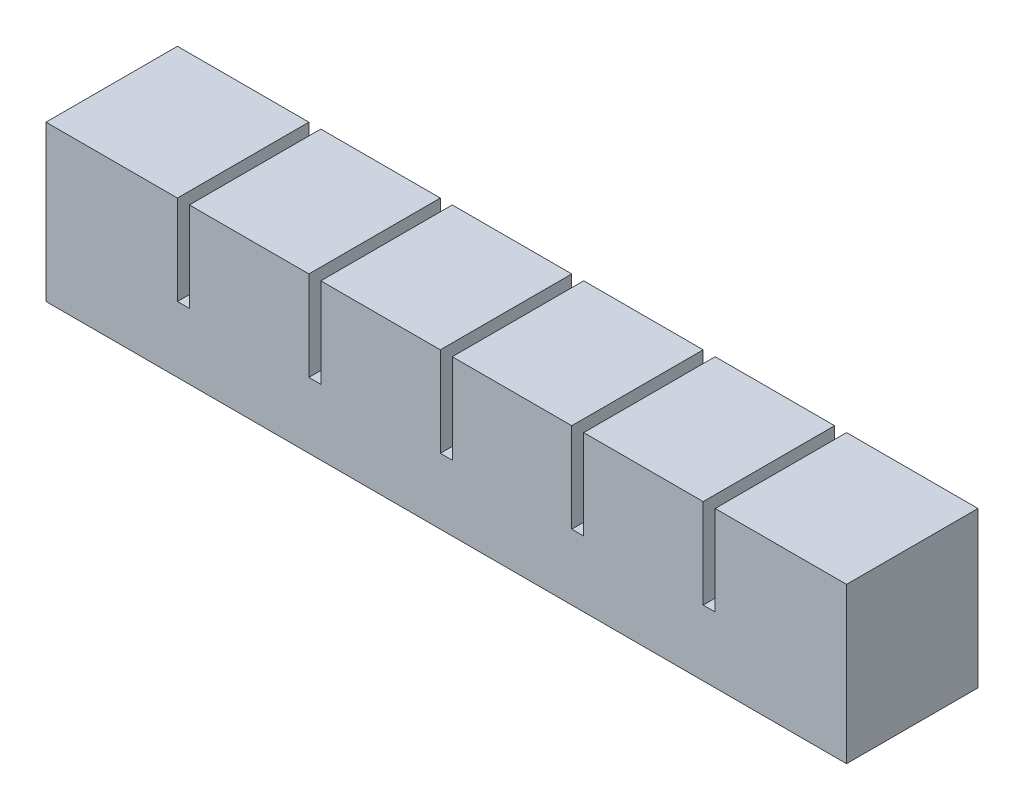
from build123d import *

# Parameters (mm, degrees)
SKETCH1_W           = 20
SKETCH1_H           = 20
BOSS_EXTRUDE1_DEPTH = 22
SKETCH2_W           = 8
SKETCH2_H           = 10
CUT_EXTRUDE1_DEPTH  = 14
SKETCH3_W           = 22
SKETCH3_H           = 5
BOSS_EXTRUDE2_DEPTH = 2
LPATTERN1_COUNT     = 6
LPATTERN1_PITCH     = 22
SKETCH4_W           = 22
SKETCH4_H           = 15
BOSS_EXTRUDE3_DEPTH = 2
SKETCH5_W           = 22
SKETCH5_H           = 20
BOSS_EXTRUDE4_DEPTH = 2
SKETCH6_W           = 118
SKETCH6_H           = 2
CUT_EXTRUDE2_DEPTH  = 2
SKETCH7_W           = 134
SKETCH7_H           = 22
BOSS_EXTRUDE5_DEPTH = 6


with BuildPart() as part:
    # Sketch1 → Boss-Extrude1 (new body)
    with BuildSketch(Plane.XY):
        with Locations((10, 10)):
            Rectangle(SKETCH1_W, SKETCH1_H)
    extrude(amount=BOSS_EXTRUDE1_DEPTH)

    # Sketch2 → Cut-Extrude1 (cut)
    with BuildSketch(Plane.XZ):
        with Locations((10, 11)):
            Rectangle(SKETCH2_W, SKETCH2_H)
    extrude(amount=-CUT_EXTRUDE1_DEPTH, mode=Mode.SUBTRACT)

    # Sketch3 → Boss-Extrude2 (add)
    with BuildSketch(Plane(origin=(20, 0, 0), x_dir=(0, 0, -1), z_dir=(1, 0, 0))):
        with Locations((-11, 2.5)):
            Rectangle(SKETCH3_W, SKETCH3_H)
    extrude(amount=BOSS_EXTRUDE2_DEPTH)


with BuildPart() as lpattern1_1:
    # LPattern1: pattern copy
    add(part.part.moved(Location(Vector(1, 0, 0) * (1 * LPATTERN1_PITCH))))


with BuildPart() as lpattern1_2:
    # LPattern1: pattern copy
    add(part.part.moved(Location(Vector(1, 0, 0) * (2 * LPATTERN1_PITCH))))


with BuildPart() as lpattern1_3:
    # LPattern1: pattern copy
    add(part.part.moved(Location(Vector(1, 0, 0) * (3 * LPATTERN1_PITCH))))


with BuildPart() as lpattern1_4:
    # LPattern1: pattern copy
    add(part.part.moved(Location(Vector(1, 0, 0) * (4 * LPATTERN1_PITCH))))


with BuildPart() as lpattern1_5:
    # LPattern1: pattern copy
    add(part.part.moved(Location(Vector(1, 0, 0) * (5 * LPATTERN1_PITCH))))


with BuildPart() as lpattern1_1_1:
    add(lpattern1_1.part)

    # Combine1: union LPattern1_2, LPattern1_3, LPattern1_4, LPattern1_5, part
    add(lpattern1_2.part)
    add(lpattern1_3.part)
    add(lpattern1_4.part)
    add(lpattern1_5.part)
    add(part.part)

    # Sketch4 → Boss-Extrude3 (add)
    with BuildSketch(Plane(origin=(130, 0, 0), x_dir=(0, 0, -1), z_dir=(1, 0, 0))):
        with Locations((-11, 12.5)):
            Rectangle(SKETCH4_W, SKETCH4_H)
    extrude(amount=BOSS_EXTRUDE3_DEPTH)

    # Sketch5 → Boss-Extrude4 (add)
    with BuildSketch(Plane.ZY):
        with Locations((11, 10)):
            Rectangle(SKETCH5_W, SKETCH5_H)
    extrude(amount=BOSS_EXTRUDE4_DEPTH)

    # Sketch6 → Cut-Extrude2 (cut)
    with BuildSketch(Plane(origin=(0, 0, 0), x_dir=(-1, 0, 0), z_dir=(0, -1, 0))):
        with Locations((-65, -11)):
            Rectangle(SKETCH6_W, SKETCH6_H)
    extrude(amount=-CUT_EXTRUDE2_DEPTH, mode=Mode.SUBTRACT)

    # Sketch7 → Boss-Extrude5 (add)
    with BuildSketch(Plane(origin=(0, 0, 0), x_dir=(-1, 0, 0), z_dir=(0, -1, 0))):
        with Locations((-65, -11)):
            Rectangle(SKETCH7_W, SKETCH7_H)
    extrude(amount=BOSS_EXTRUDE5_DEPTH)


solid = lpattern1_1_1.part
